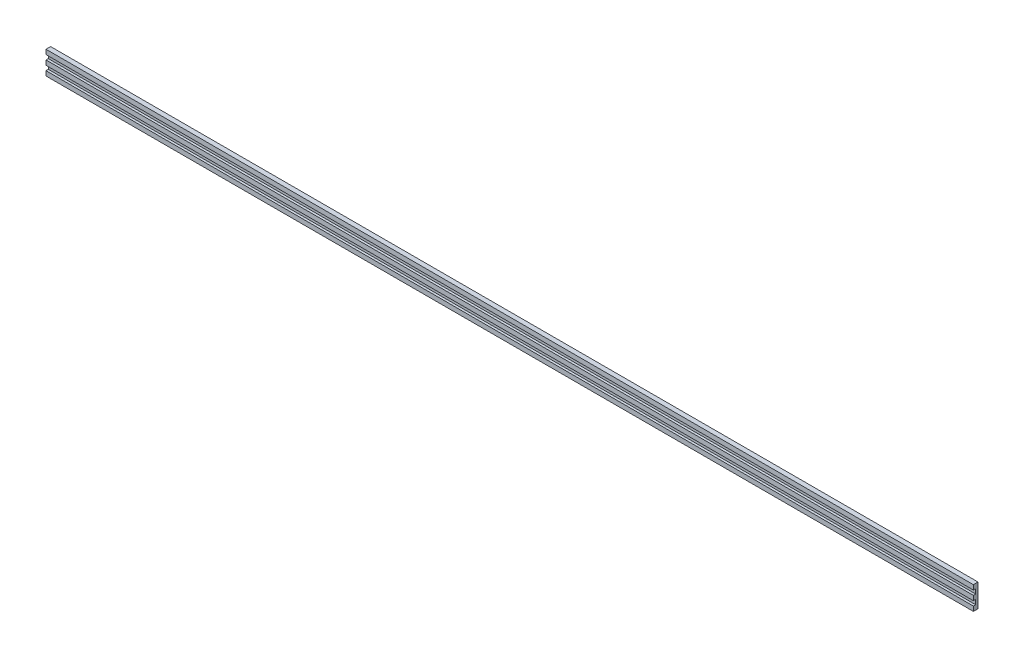
from build123d import *

# Parameters (mm, degrees)
SKETCH1_W           = 200
SKETCH1_H           = 5
BOSS_EXTRUDE1_DEPTH = 0.5
SKETCH2_W           = 200
SKETCH2_H           = 1
BOSS_EXTRUDE2_DEPTH = 0.5


with BuildPart() as part:
    # Sketch1 → Boss-Extrude1 (new body)
    with BuildSketch(Plane.XY):
        Rectangle(SKETCH1_W, SKETCH1_H)
    extrude(amount=BOSS_EXTRUDE1_DEPTH)

    # Sketch2 → Boss-Extrude2 (add)
    with BuildSketch(Plane.XY.offset(0.5)):
        with Locations((0, 2)):
            Rectangle(SKETCH2_W, SKETCH2_H)
        Rectangle(SKETCH2_W, SKETCH2_H)
        with Locations((0, -2)):
            Rectangle(SKETCH2_W, SKETCH2_H)
    extrude(amount=BOSS_EXTRUDE2_DEPTH)


solid = part.part
